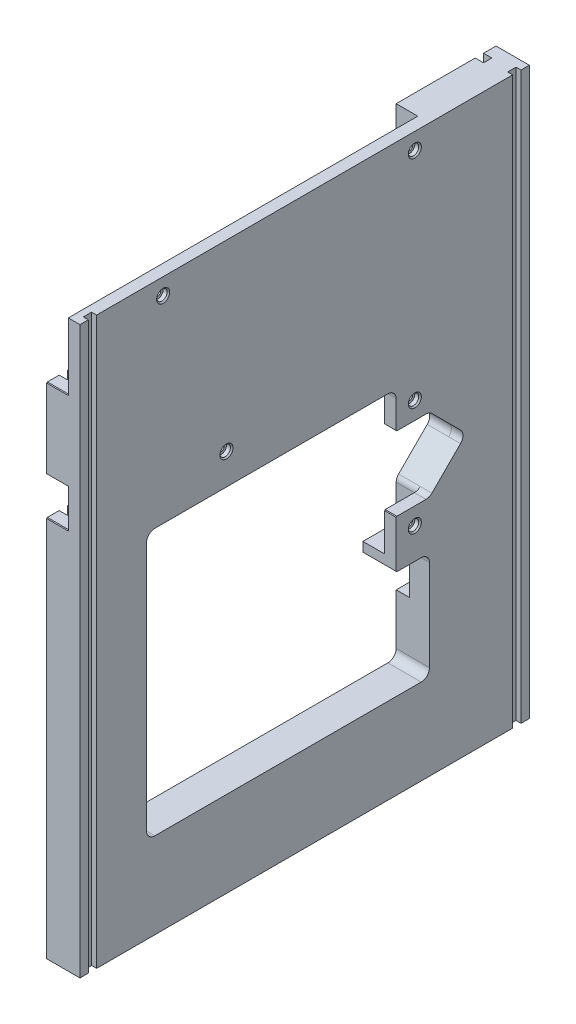
from build123d import *

# Parameters (mm, degrees)
SKETCH2_W                     = 342.9
SKETCH2_H                     = 431.8
BASE_DEPTH                    = 25.4
CUT_EXTRUDE3_REACH            = 27.4
NC_POCKET_DEPTH               = 16.51
FILLET9_R                     = 6.35
FILLET6_R                     = 6.35
CBORE_FOR_M4_SHCS1_AT_2_COUNT = 2
CBORE_FOR_M4_SHCS1_AT_2_PITCH = 192.024
CBORE_FOR_M4_SHCS1_AT_3_COUNT = 2
CBORE_FOR_M4_SHCS1_AT_3_PITCH = 313.675937134
CBORE_FOR_M4_SHCS1_AT_4_COUNT = 2
CBORE_FOR_M4_SHCS1_AT_4_PITCH = 253.241439295
CBORE_FOR_M4_SHCS1_AT_5_COUNT = 2
CBORE_FOR_M4_SHCS1_AT_5_PITCH = 135.860323862
SKETCH18_R                    = 7.1755
CUT_EXTRUDE4_DEPTH            = 1.016
F_3_8_16_TAPPED_HOLE1_D       = 7.9375
F_3_8_16_TAPPED_HOLE1_DEPTH   = 27.94
F_3_8_16_TAPPED_HOLE1_TIP     = 2.384665582
F_3_8_16_TAPPED_HOLE2_D       = 7.9375
F_3_8_16_TAPPED_HOLE2_DEPTH   = 20.32
F_3_8_16_TAPPED_HOLE2_TIP     = 2.384665582
CUT_EXTRUDE5_REACH            = 10.89
FILLET1_R                     = 6.35
FILLET2_R                     = 6.35
CHAMFER1_SIZE                 = 0.508
SKETCH21_W                    = 6.35
SKETCH21_H                    = 431.8
CUT_EXTRUDE6_DEPTH            = 6.35
SKETCH22_W                    = 6.35
SKETCH22_H                    = 431.8
CUT_EXTRUDE7_DEPTH            = 3.81
SKETCH23_W                    = 33.02
SKETCH23_H                    = 48.26
CUT_EXTRUDE8_DEPTH            = 10.16
FILLET10_R                    = 6.35


with BuildPart() as part:
    # Sketch2 → Base (new body)
    with BuildSketch(Plane(origin=(0, 0, 0), x_dir=(0, 0, -1), z_dir=(1, 0, 0))):
        with Locations((-44.038996764, -78.624919094)):
            Rectangle(SKETCH2_W, SKETCH2_H)
    extrude(amount=BASE_DEPTH)

    # Sketch3 → Cut-Extrude3 (cut, up to next)
    with BuildSketch(Plane(origin=(0, 0, 0), x_dir=(0, 0, -1), z_dir=(1, 0, 0)), mode=Mode.PRIVATE) as cut_extrude3_sk1:
        Polygon((-164.688996764, -25.919919094), (-164.688996764, -229.119919094), (51.211003236, -229.119919094), (51.211003236, -146.950919094), (25.811003236, -146.950919094), (25.811003236, -25.919919094), align=None)
    cut_extrude3_tool1 = extrude(cut_extrude3_sk1.sketch, amount=CUT_EXTRUDE3_REACH, mode=Mode.PRIVATE) & part.part
    add(cut_extrude3_tool1.solids().sort_by_distance((0, -130.615794, 63.91645))[0], mode=Mode.SUBTRACT)

    # Sketch4 → NC pocket (cut)
    with BuildSketch(Plane(origin=(0, 0, 0), x_dir=(0, 0, -1), z_dir=(1, 0, 0))):
        Polygon((19.461003236, -18.299919094), (-158.338996764, -18.299919094), (-158.338996764, -25.919919094), (-164.688996764, -25.919919094), (-164.688996764, -12.583714933), (-164.688996764, -3.059919094), (-215.488996764, -3.059919094), (-215.488996764, 25.515080906), (-164.688996764, 25.515080906), (-164.688996764, 86.475080906), (-215.488996764, 86.475080906), (-215.488996764, 90.285080906), (-215.488996764, 137.275080906), (-202.788996764, 137.275080906), (51.211003236, 137.275080906), (51.211003236, -15.124919094), (51.211003236, -53.859919094), (79.405003236, -82.053919094), (51.211003236, -110.247919094), (51.211003236, -136.155919094), (51.211003236, -146.950919094), (44.861003236, -146.950919094), (44.861003236, -139.330919094), (25.811003236, -139.330919094), (25.811003236, -25.919919094), (19.461003236, -25.919919094), align=None)
    extrude(amount=NC_POCKET_DEPTH, mode=Mode.SUBTRACT)

    # Fillet9
    fillet9_edges = [part.edges().sort_by_distance(p)[0] for p in [
        (8.255, -53.859919094, -51.211003236),
        (8.255, -110.247919094, -51.211003236),
    ]]
    fillet(fillet9_edges, radius=FILLET9_R)

    # Fillet6
    fillet6_edges = [part.edges().sort_by_distance(p)[0] for p in [
        (8.255, -82.053919094, -79.405003236),
    ]]
    fillet(fillet6_edges, radius=FILLET6_R)

    # Sketch10 → CBORE for M4 SHCS1 (revolve, cut)
    with BuildSketch(Plane(origin=(25.4, 124.575080906, 151.988996764), x_dir=(0, 0, -1), z_dir=(0, 1, 0))):
        Polygon((0, 0), (0, 8.89), (2.15, 8.89), (2.15, 4), (4, 4), (4, 1), (5, 0), align=None)
    cbore_for_m4_shcs1 = revolve(axis=Axis((31.75, 124.575080906, 151.988996764), (-1, 0, 0)), mode=Mode.SUBTRACT)

    # CBORE for M4 SHCS1 at 2: CBORE for M4 SHCS1 ×2
    with Locations(*[(0, 0, -i * CBORE_FOR_M4_SHCS1_AT_2_PITCH) for i in range(1, CBORE_FOR_M4_SHCS1_AT_2_COUNT)]):
        add(cbore_for_m4_shcs1, mode=Mode.SUBTRACT)

    # CBORE for M4 SHCS1 at 3: CBORE for M4 SHCS1 ×2
    with Locations(*[Vector(0, -0.790723708, -0.612173193) * (i * CBORE_FOR_M4_SHCS1_AT_3_PITCH) for i in range(1, CBORE_FOR_M4_SHCS1_AT_3_COUNT)]):
        add(cbore_for_m4_shcs1, mode=Mode.SUBTRACT)

    # CBORE for M4 SHCS1 at 4: CBORE for M4 SHCS1 ×2
    with Locations(*[Vector(0, -0.651947013, -0.758264526) * (i * CBORE_FOR_M4_SHCS1_AT_4_PITCH) for i in range(1, CBORE_FOR_M4_SHCS1_AT_4_COUNT)]):
        add(cbore_for_m4_shcs1, mode=Mode.SUBTRACT)

    # CBORE for M4 SHCS1 at 5: CBORE for M4 SHCS1 ×2
    with Locations(*[Vector(0, -0.934783581, -0.355217761) * (i * CBORE_FOR_M4_SHCS1_AT_5_PITCH) for i in range(1, CBORE_FOR_M4_SHCS1_AT_5_COUNT)]):
        add(cbore_for_m4_shcs1, mode=Mode.SUBTRACT)

    # Sketch18 → Cut-Extrude4 (cut)
    with BuildSketch(Plane.ZY.offset(-16.51)):
        with Locations((-40.035003236, 124.575080906)):
            Circle(SKETCH18_R)
        with Locations((151.988996764, 124.575080906)):
            Circle(SKETCH18_R)
        with Locations((103.728996764, -2.424919094)):
            Circle(SKETCH18_R)
        with Locations((-40.035003236, -40.524919094)):
            Circle(SKETCH18_R)
        with Locations((-40.035003236, -123.455919094)):
            Circle(SKETCH18_R)
    extrude(amount=-CUT_EXTRUDE4_DEPTH, mode=Mode.SUBTRACT)

    # 3/8-16 Tapped Hole1
    with Locations(Plane(origin=(12.7, -294.524919094, -70.261003236), x_dir=(0, 0, -1), z_dir=(0, -1, 0))):
        with Locations((0, 0), (-114.3, 0), (-228.6, 0)):
            Hole(F_3_8_16_TAPPED_HOLE1_D / 2, depth=F_3_8_16_TAPPED_HOLE1_DEPTH)
            with Locations((0, 0, -(F_3_8_16_TAPPED_HOLE1_DEPTH + F_3_8_16_TAPPED_HOLE1_TIP / 2))):  # 118° drill point
                Cone(0, F_3_8_16_TAPPED_HOLE1_D / 2, F_3_8_16_TAPPED_HOLE1_TIP, mode=Mode.SUBTRACT)

    # 3/8-16 Tapped Hole2
    with Locations(Plane.ZY):
        with Locations((188.501496764, -220.864919094), (188.501496764, -162.444919094), (-100.423503236, -220.864919094), (-100.423503236, -162.444919094)):
            Hole(F_3_8_16_TAPPED_HOLE2_D / 2, depth=F_3_8_16_TAPPED_HOLE2_DEPTH)
            with Locations((0, 0, -(F_3_8_16_TAPPED_HOLE2_DEPTH + F_3_8_16_TAPPED_HOLE2_TIP / 2))):  # 118° drill point
                Cone(0, F_3_8_16_TAPPED_HOLE2_D / 2, F_3_8_16_TAPPED_HOLE2_TIP, mode=Mode.SUBTRACT)

    # Sketch20 → Cut-Extrude5 (cut, up to next)
    with BuildSketch(Plane.ZY.offset(-16.51), mode=Mode.PRIVATE) as cut_extrude5_sk1:
        Polygon((-51.211003236, -53.859919094), (-25.811003236, -53.859919094), (-25.811003236, -110.247919094), (-51.211003236, -110.247919094), (-79.405003236, -82.053919094), align=None)
    cut_extrude5_tool1 = extrude(cut_extrude5_sk1.sketch, amount=-CUT_EXTRUDE5_REACH, mode=Mode.PRIVATE) & part.part
    add(cut_extrude5_tool1.solids().sort_by_distance((16.51, -82.053919, -46.398071))[0], mode=Mode.SUBTRACT)

    # Fillet1
    fillet1_edges = [part.edges().sort_by_distance(p)[0] for p in [
        (20.955, -25.919919094, 164.688996764),
        (12.7, -229.119919094, 164.688996764),
        (12.7, -229.119919094, -51.211003236),
        (20.955, -146.950919094, -51.211003236),
        (20.955, -25.919919094, -25.811003236),
    ]]
    fillet(fillet1_edges, radius=FILLET1_R)

    # Fillet2
    fillet2_edges = [part.edges().sort_by_distance(p)[0] for p in [
        (20.955, -82.053919094, -79.405003236),
        (20.955, -110.247919094, -51.211003236),
        (20.955, -53.859919094, -51.211003236),
    ]]
    fillet(fillet2_edges, radius=FILLET2_R)

    # Chamfer1
    chamfer1_edges = [part.edges().sort_by_distance(p)[0] for p in [
        (12.7, -146.950919094, -25.811003236),
        (20.955, -53.859919094, -25.811003236),
        (20.955, -110.247919094, -25.811003236),
        (8.255, 86.475080906, 215.488996764),
        (8.255, 86.475080906, 164.688996764),
        (8.255, 25.515080906, 164.688996764),
        (8.255, 25.515080906, 215.488996764),
        (8.255, -3.059919094, 215.488996764),
        (8.255, -3.059919094, 164.688996764),
    ]]
    chamfer(chamfer1_edges, length=CHAMFER1_SIZE)

    # Sketch21 → Cut-Extrude6 (cut)
    with BuildSketch(Plane.ZY):
        with Locations((202.788996764, -78.624919094)):
            Rectangle(SKETCH21_W, SKETCH21_H)
        with Locations((-114.711003236, -78.624919094)):
            Rectangle(SKETCH21_W, SKETCH21_H)
    extrude(amount=-CUT_EXTRUDE6_DEPTH, mode=Mode.SUBTRACT)

    # Sketch22 → Cut-Extrude7 (cut)
    with BuildSketch(Plane(origin=(25.4, 0, 0), x_dir=(0, 0, -1), z_dir=(1, 0, 0))):
        with Locations((-205.963996764, -78.624919094)):
            Rectangle(SKETCH22_W, SKETCH22_H)
        with Locations((117.886003236, -78.624919094)):
            Rectangle(SKETCH22_W, SKETCH22_H)
    extrude(amount=-CUT_EXTRUDE7_DEPTH, mode=Mode.SUBTRACT)

    # Sketch23 → Cut-Extrude8 (cut)
    with BuildSketch(Plane.ZY):
        with Locations((-67.721003236, -159.904919094)):
            Rectangle(SKETCH23_W, SKETCH23_H)
    extrude(amount=-CUT_EXTRUDE8_DEPTH, mode=Mode.SUBTRACT)

    # Fillet10
    fillet10_edges = [part.edges().sort_by_distance(p)[0] for p in [
        (5.08, -184.034919094, -84.231003236),
        (5.08, -135.774919094, -84.231003236),
    ]]
    fillet(fillet10_edges, radius=FILLET10_R)


solid = part.part
